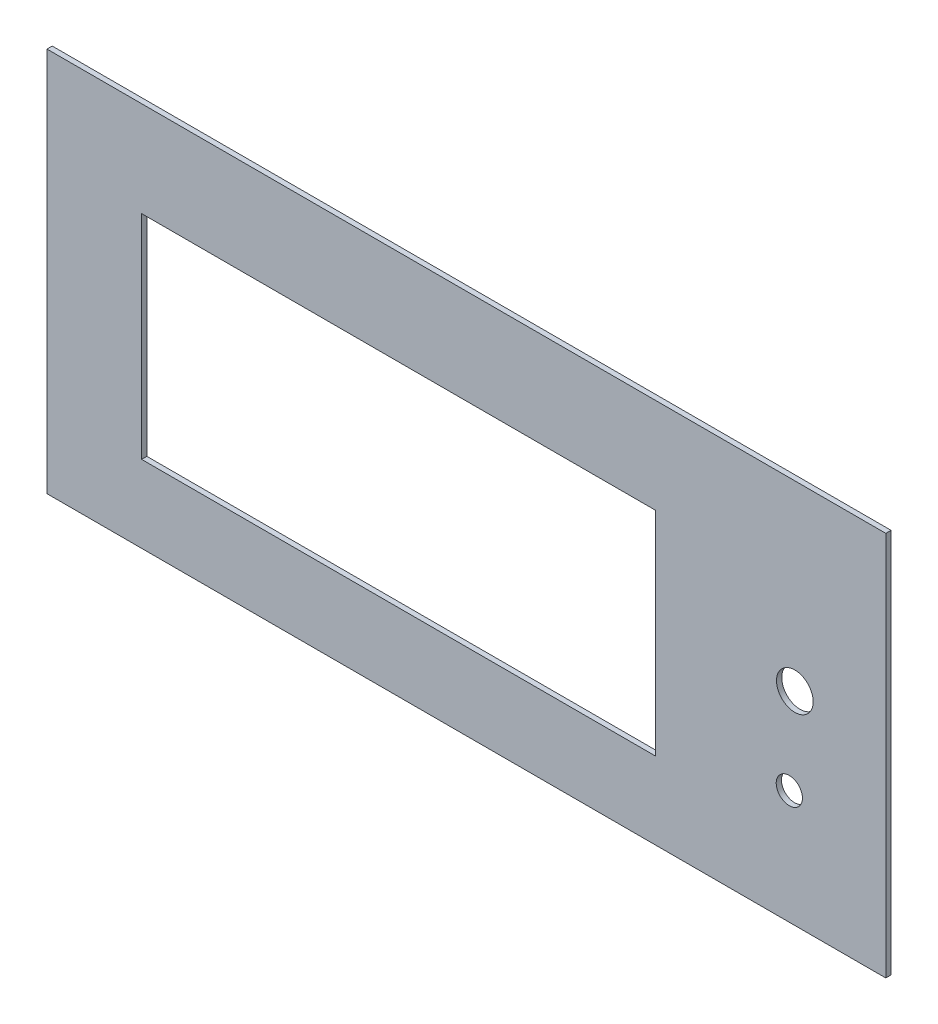
from build123d import *

# Parameters (mm, degrees)
SZKIC1_W                    = 160
SZKIC1_H                    = 73.454801658
SZKIC1_R                    = 2.5
SZKIC1_R_2                  = 3.5
SZKIC1_W_2                  = 98
SZKIC1_H_2                  = 40.6
DODANIE_WYCI_GNI_CIE1_DEPTH = 1


with BuildPart() as part:
    # Szkic1 → Dodanie-wyciągnięcie1 (new body)
    with BuildSketch(Plane.XY):
        with Locations((0.546139269, -4.272599171)):
            Rectangle(SZKIC1_W, SZKIC1_H)
        with Locations((62.146139269, -19.245198342)):
            Circle(SZKIC1_R, mode=Mode.SUBTRACT)
        with Locations((63.196139269, -2.295198342)):
            Circle(SZKIC1_R_2, mode=Mode.SUBTRACT)
        with Locations((-12.4, -6)):
            Rectangle(SZKIC1_W_2, SZKIC1_H_2, mode=Mode.SUBTRACT)
    extrude(amount=DODANIE_WYCI_GNI_CIE1_DEPTH)


solid = part.part
